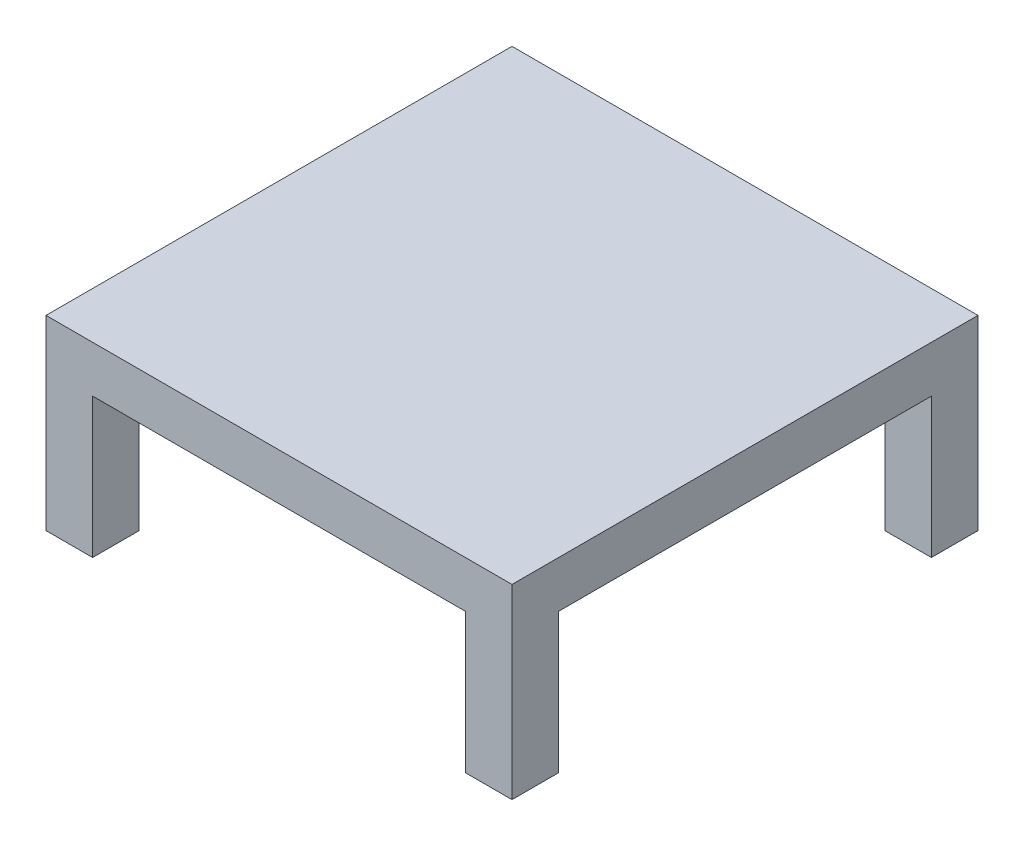
from build123d import *

# Parameters (mm, degrees)
SKETCH2_W           = 100
SKETCH2_H           = 100
BOSS_EXTRUDE1_DEPTH = 10
SKETCH3_W           = 10
SKETCH3_H           = 10
BOSS_EXTRUDE2_DEPTH = 30


with BuildPart() as part:
    # Sketch2 → Boss-Extrude1 (new body)
    with BuildSketch(Plane(origin=(0, 0, 0), x_dir=(1, 0, 0), z_dir=(0, 1, 0))):
        Rectangle(SKETCH2_W, SKETCH2_H)
    extrude(amount=BOSS_EXTRUDE1_DEPTH)

    # Sketch3 → Boss-Extrude2 (add)
    with BuildSketch(Plane(origin=(0, 0, 0), x_dir=(-1, 0, 0), z_dir=(0, -1, 0))):
        with Locations((-45, -45)):
            Rectangle(SKETCH3_W, SKETCH3_H)
        with Locations((45, -45)):
            Rectangle(SKETCH3_W, SKETCH3_H)
        with Locations((45, 45)):
            Rectangle(SKETCH3_W, SKETCH3_H)
        with Locations((-45, 45)):
            Rectangle(SKETCH3_W, SKETCH3_H)
    extrude(amount=BOSS_EXTRUDE2_DEPTH)


solid = part.part
